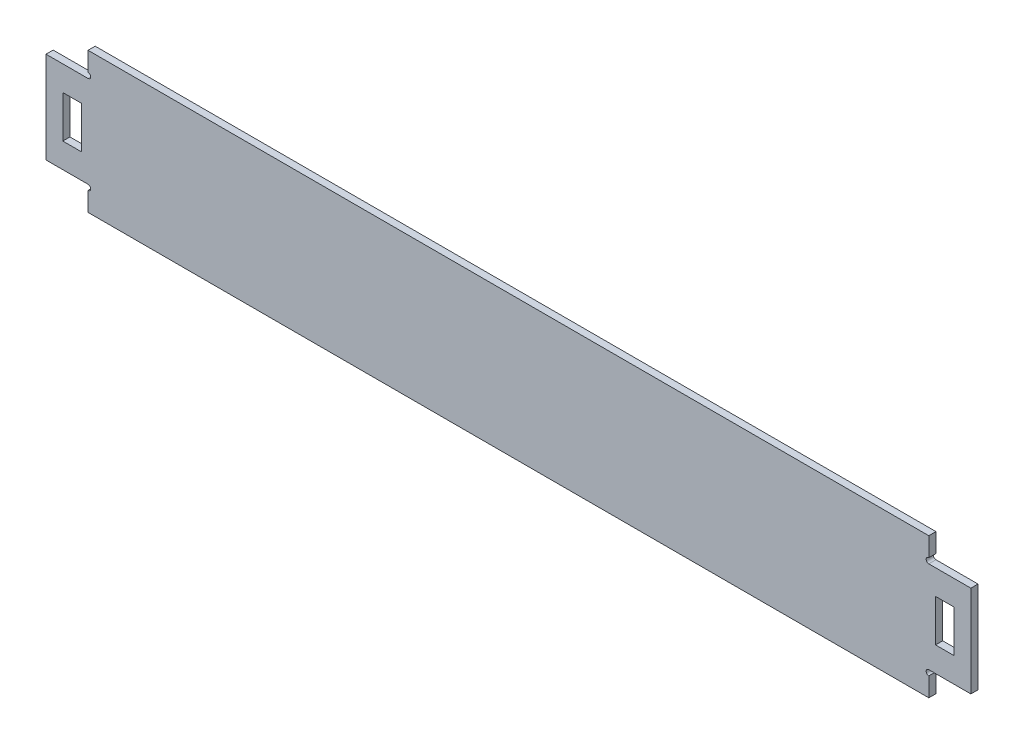
from build123d import *

# Parameters (mm, degrees)
SKETCH1_W           = 22
SKETCH1_H           = 50
BOSS_EXTRUDE1_DEPTH = 4.25


with BuildPart() as part:
    # Sketch1 → Boss-Extrude1 (new body, symmetric)
    with BuildSketch(Plane.XY):
        with BuildLine():
            Line((-498.569276331, 84.968707483), (501.430723669, 84.968707483))
            Line((501.430723669, 84.968707483), (501.430723669, 62.328707483))
            ThreePointArc((501.430723669, 62.328707483), (498.250723669, 59.148707483), (501.430723669, 55.968707483))
            Line((501.430723669, 55.968707483), (551.430723669, 55.968707483))
            Line((551.430723669, 55.968707483), (551.430723669, -53.031292517))
            Line((551.430723669, -53.031292517), (501.430723669, -53.031292517))
            ThreePointArc((501.430723669, -53.031292517), (498.250723669, -56.211292517), (501.430723669, -59.391292517))
            Line((501.430723669, -59.391292517), (501.430723669, -82.031292517))
            Line((501.430723669, -82.031292517), (-498.569276331, -82.031292517))
            Line((-498.569276331, -82.031292517), (-498.569276331, -59.391292517))
            ThreePointArc((-498.569276331, -59.391292517), (-495.389276331, -56.211292517), (-498.569276331, -53.031292517))
            Line((-498.569276331, -53.031292517), (-548.569276331, -53.031292517))
            Line((-548.569276331, -53.031292517), (-548.569276331, 55.968707483))
            Line((-548.569276331, 55.968707483), (-498.569276331, 55.968707483))
            ThreePointArc((-498.569276331, 55.968707483), (-495.389276331, 59.148707483), (-498.569276331, 62.328707483))
            Line((-498.569276331, 62.328707483), (-498.569276331, 84.968707483))
        make_face()
        with Locations((520.430723669, 1.468707483)):
            Rectangle(SKETCH1_W, SKETCH1_H, mode=Mode.SUBTRACT)
        with Locations((-517.569276331, 1.468707483)):
            Rectangle(SKETCH1_W, SKETCH1_H, mode=Mode.SUBTRACT)
    extrude(amount=BOSS_EXTRUDE1_DEPTH, both=True)


solid = part.part
